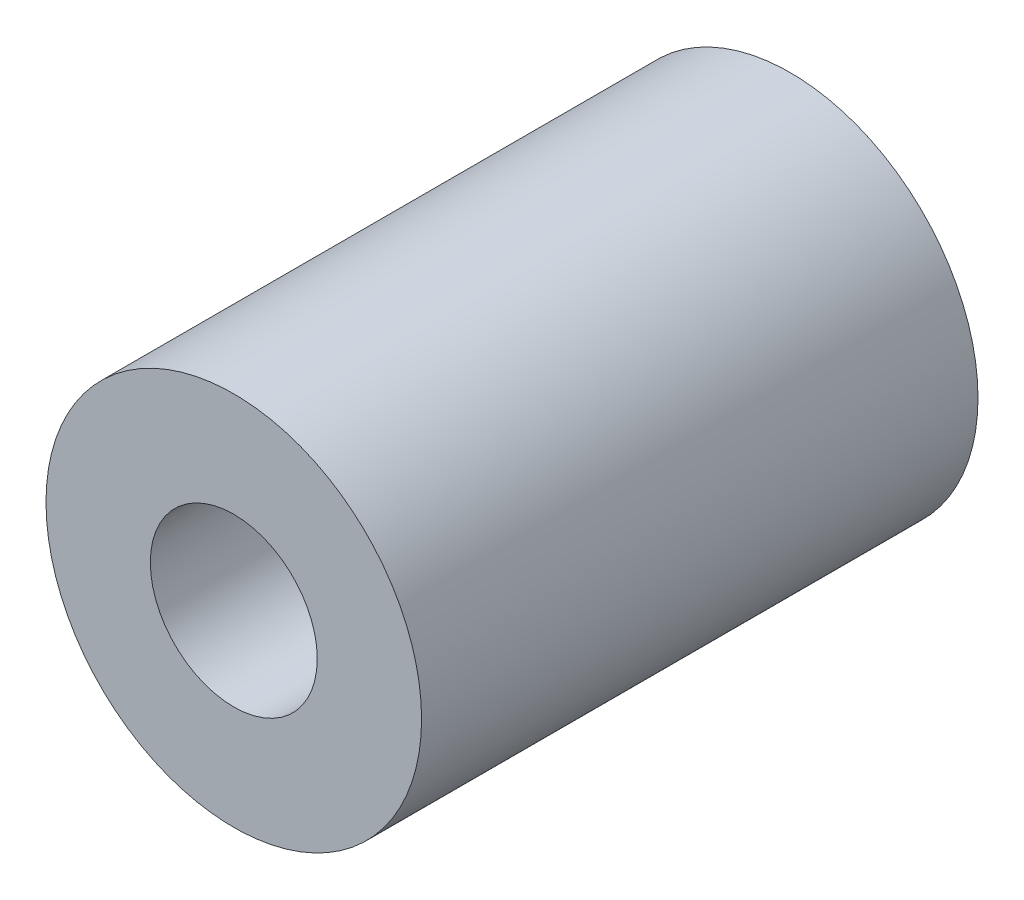
from build123d import *

# Parameters (mm, degrees)
SKETCH2_R           = 13.5
BOSS_EXTRUDE1_DEPTH = 40
SKETCH3_R           = 6
CUT_EXTRUDE1_DEPTH  = 40


with BuildPart() as part:
    # Sketch2 → Boss-Extrude1 (new body)
    with BuildSketch(Plane.XY):
        Circle(SKETCH2_R)
    extrude(amount=BOSS_EXTRUDE1_DEPTH)

    # Sketch3 → Cut-Extrude1 (cut)
    with BuildSketch(Plane.XY.offset(40)):
        Circle(SKETCH3_R)
    extrude(amount=-CUT_EXTRUDE1_DEPTH, mode=Mode.SUBTRACT)


solid = part.part
